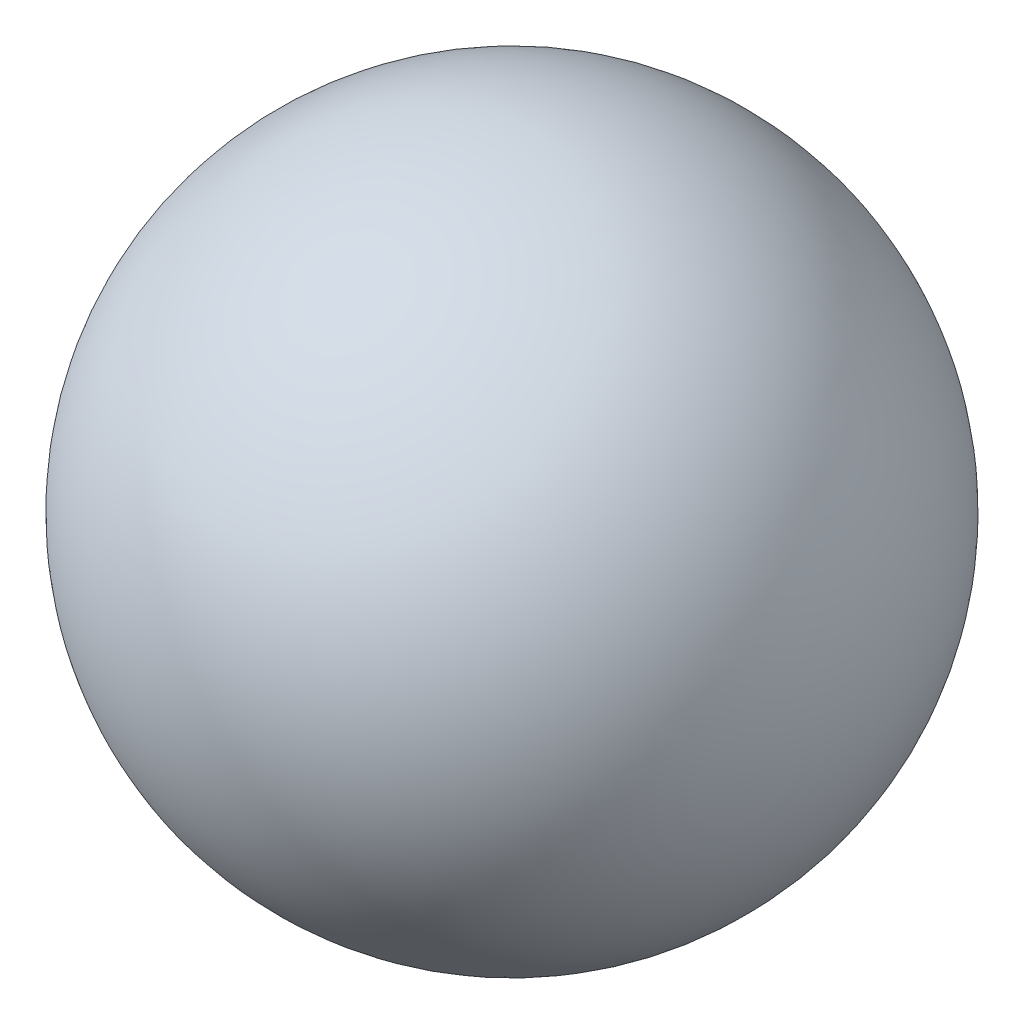
from build123d import *


with BuildPart() as part:
    # Sketch1 one side → Revolve1 (revolve)
    with BuildSketch(Plane(origin=(0, 0, 0), x_dir=(1, 0, 0), z_dir=(0, 1, 0))):
        with BuildLine():
            ThreePointArc((0, -20), (14.142135624, -14.142135624), (20, 0))
            ThreePointArc((20, 0), (14.142135624, 14.142135624), (0, 20))
            Line((0, 20), (0, -20))
        make_face()
    revolve(axis=Axis((0, 0, -20), (0, 0, 1)))


solid = part.part
